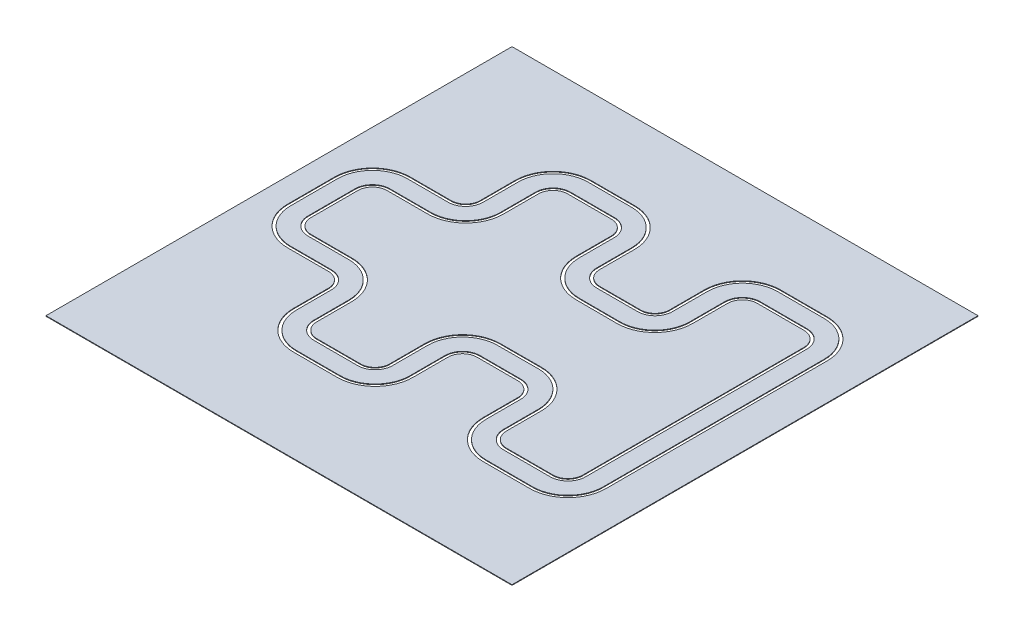
from build123d import *

# Parameters (mm, degrees)
BOSS_EXTRUDE1_DEPTH   = 10
BOSS_EXTRUDE1_2_DEPTH = 10
SKETCH1_W             = 8000
SKETCH1_H             = 8000
BOSS_EXTRUDE1_3_DEPTH = 10


with BuildPart() as part:
    # Sketch1 → Boss-Extrude1 (new body)
    with BuildSketch(Plane(origin=(0, 0, 0), x_dir=(1, 0, 0), z_dir=(0, 1, 0))):
        with BuildLine():
            Line((-1771.800598165, -1038.917055483), (-1771.800598165, -1638.917055483))
            ThreePointArc((-1771.800598165, -1638.917055483), (-1698.577293461, -1815.69375078), (-1521.800598165, -1888.917055483))
            Line((-1521.800598165, -1888.917055483), (-770.59837107, -1888.917055483))
            ThreePointArc((-770.59837107, -1888.917055483), (-593.821675773, -1815.69375078), (-520.59837107, -1638.917055483))
            Line((-520.59837107, -1638.917055483), (-520.59837107, -1037.241131973))
            ThreePointArc((-520.59837107, -1037.241131973), (-330.810688722, -578.215399925), (127.723544874, -387.243298104))
            Line((127.723544874, -387.243298104), (827.921145778, -385.435614494))
            ThreePointArc((827.921145778, -385.435614494), (1288.624961882, -575.221130711), (1479.599229835, -1035.433448363))
            Line((1479.599229835, -1035.433448363), (1479.599229835, -1633.753192334))
            ThreePointArc((1479.599229835, -1633.753192334), (1554.343425249, -1814.201642611), (1734.791875526, -1888.945838025))
            Line((1734.791875526, -1888.945838025), (2534.791875526, -1888.945838025))
            ThreePointArc((2534.791875526, -1888.945838025), (2715.240325804, -1814.201642611), (2789.984521218, -1633.753192334))
            Line((2789.984521218, -1633.753192334), (2789.984521218, -1035.433448363))
            Line((2789.984521218, -1035.433448363), (2789.984521218, 1563.280738064))
            Line((2789.984521218, 1563.280738064), (2789.984521218, 2161.600482035))
            ThreePointArc((2789.984521218, 2161.600482035), (2715.240326037, 2342.04893175), (2534.791876322, 2416.793126931))
            Line((2534.791876322, 2416.793126931), (1734.791876322, 2416.793126931))
            ThreePointArc((1734.791876322, 2416.793126931), (1554.343425811, 2342.04893208), (1479.599229835, 2161.600482035))
            Line((1479.599229835, 2161.600482035), (1479.599229835, 1563.280738064))
            ThreePointArc((1479.599229835, 1563.280738064), (1288.624961882, 1103.068420413), (827.921145778, 913.282904196))
            Line((827.921145778, 913.282904196), (127.723544874, 915.090587806))
            ThreePointArc((127.723544874, 915.090587806), (-330.810688722, 1106.062689627), (-520.59837107, 1565.088421674))
            Line((-520.59837107, 1565.088421674), (-520.59837107, 2166.764345185))
            ThreePointArc((-520.59837107, 2166.764345185), (-593.821675773, 2343.541040481), (-770.59837107, 2416.764345185))
            Line((-770.59837107, 2416.764345185), (-1521.800598165, 2416.764345185))
            ThreePointArc((-1521.800598165, 2416.764345185), (-1698.577293461, 2343.541040481), (-1771.800598165, 2166.764345185))
            Line((-1771.800598165, 2166.764345185), (-1771.800598165, 1566.764345185))
            ThreePointArc((-1771.800598165, 1566.764345185), (-1962.181190393, 1107.144937413), (-2421.800598165, 916.764345185))
            Line((-2421.800598165, 916.764345185), (-3121.800598165, 916.764345185))
            ThreePointArc((-3121.800598165, 916.764345185), (-3298.577293461, 843.541040481), (-3371.800598165, 666.764345185))
            Line((-3371.800598165, 666.764345185), (-3371.800598165, -138.917055483))
            ThreePointArc((-3371.800598165, -138.917055483), (-3298.577293461, -315.69375078), (-3121.800598165, -388.917055483))
            Line((-3121.800598165, -388.917055483), (-2421.800598165, -388.917055483))
            ThreePointArc((-2421.800598165, -388.917055483), (-1962.181190393, -579.297647712), (-1771.800598165, -1038.917055483))
        make_face()
    extrude(amount=BOSS_EXTRUDE1_DEPTH)


with BuildPart() as body_2:
    # Sketch1 → Boss-Extrude1 2 (new body)
    with BuildSketch(Plane(origin=(0, 0, 0), x_dir=(1, 0, 0), z_dir=(0, 1, 0))):
        with BuildLine():
            Line((-2121.800598165, -1638.917055483), (-2121.800598165, -1038.917055483))
            ThreePointArc((-2121.800598165, -1038.917055483), (-2209.668563809, -826.785021127), (-2421.800598165, -738.917055483))
            Line((-2421.800598165, -738.917055483), (-3121.800598165, -738.917055483))
            ThreePointArc((-3121.800598165, -738.917055483), (-3546.064666876, -563.181124195), (-3721.800598165, -138.917055483))
            Line((-3721.800598165, -138.917055483), (-3721.800598165, 666.764345185))
            ThreePointArc((-3721.800598165, 666.764345185), (-3546.064666876, 1091.028413897), (-3121.800598165, 1266.764345185))
            Line((-3121.800598165, 1266.764345185), (-2421.800598165, 1266.764345185))
            ThreePointArc((-2421.800598165, 1266.764345185), (-2209.668563809, 1354.632310829), (-2121.800598165, 1566.764345185))
            Line((-2121.800598165, 1566.764345185), (-2121.800598165, 2166.764345185))
            ThreePointArc((-2121.800598165, 2166.764345185), (-1946.064666876, 2591.028413897), (-1521.800598165, 2766.764345185))
            Line((-1521.800598165, 2766.764345185), (-770.59837107, 2766.764345185))
            ThreePointArc((-770.59837107, 2766.764345185), (-346.334302358, 2591.028413897), (-170.59837107, 2166.764345185))
            Line((-170.59837107, 2166.764345185), (-170.59837107, 1566.764201952))
            ThreePointArc((-170.59837107, 1566.764201952), (-82.730456066, 1354.632218237), (129.401485698, 1266.764201952))
            Line((129.401485698, 1266.764201952), (829.757148713, 1266.763867573))
            ThreePointArc((829.757148713, 1266.763867573), (1041.88927538, 1354.631782296), (1129.757291945, 1566.763866778))
            Line((1129.757291945, 1566.763866778), (1129.757291945, 2166.763723545))
            ThreePointArc((1129.757291945, 2166.763723545), (1308.781633859, 2591.261720351), (1734.791876322, 2766.657095451))
            Line((1734.791876322, 2766.657095451), (2534.791876322, 2766.657095451))
            ThreePointArc((2534.791876322, 2766.657095451), (2960.802117709, 2591.261720304), (3139.826459107, 2166.763724341))
            Line((3139.826459107, 2166.763724341), (3139.826459107, 1566.763867573))
            Line((3139.826459107, 1566.763867573), (3139.826459107, -1038.916577872))
            Line((3139.826459107, -1038.916577872), (3139.826459107, -1638.916434639))
            ThreePointArc((3139.826459107, -1638.916434639), (2960.802117476, -2063.414431165), (2534.791875526, -2238.809806545))
            Line((2534.791875526, -2238.809806545), (1734.791875526, -2238.809806545))
            ThreePointArc((1734.791875526, -2238.809806545), (1308.781633576, -2063.414431165), (1129.757291945, -1638.916434639))
            Line((1129.757291945, -1638.916434639), (1129.757291945, -1038.916577872))
            ThreePointArc((1129.757291945, -1038.916577872), (1041.889275661, -826.784492876), (829.757148713, -738.916577872))
            Line((829.757148713, -738.916577872), (129.401485698, -738.916912251))
            ThreePointArc((129.401485698, -738.916912251), (-82.730456066, -826.784928535), (-170.59837107, -1038.916912251))
            Line((-170.59837107, -1038.916912251), (-170.59837107, -1638.917055483))
            ThreePointArc((-170.59837107, -1638.917055483), (-346.334302358, -2063.181124195), (-770.59837107, -2238.917055483))
            Line((-770.59837107, -2238.917055483), (-1521.800598165, -2238.917055483))
            ThreePointArc((-1521.800598165, -2238.917055483), (-1946.064666876, -2063.181124195), (-2121.800598165, -1638.917055483))
        make_face()
        with BuildLine():
            Line((-1821.800598165, -1638.917055483), (-1821.800598165, -1038.917055483))
            ThreePointArc((-1821.800598165, -1038.917055483), (-1997.536529453, -614.652986771), (-2421.800598165, -438.917055483))
            Line((-2421.800598165, -438.917055483), (-3121.800598165, -438.917055483))
            ThreePointArc((-3121.800598165, -438.917055483), (-3333.932632521, -351.049089839), (-3421.800598165, -138.917055483))
            Line((-3421.800598165, -138.917055483), (-3421.800598165, 666.764345185))
            ThreePointArc((-3421.800598165, 666.764345185), (-3333.932632521, 878.896379541), (-3121.800598165, 966.764345185))
            Line((-3121.800598165, 966.764345185), (-2421.800598165, 966.764345185))
            ThreePointArc((-2421.800598165, 966.764345185), (-1997.536529453, 1142.500276473), (-1821.800598165, 1566.764345185))
            Line((-1821.800598165, 1566.764345185), (-1821.800598165, 2166.764345185))
            ThreePointArc((-1821.800598165, 2166.764345185), (-1733.932632521, 2378.896379541), (-1521.800598165, 2466.764345185))
            Line((-1521.800598165, 2466.764345185), (-770.59837107, 2466.764345185))
            ThreePointArc((-770.59837107, 2466.764345185), (-558.466336714, 2378.896379541), (-470.59837107, 2166.764345185))
            Line((-470.59837107, 2166.764345185), (-470.59837107, 1565.13607002))
            ThreePointArc((-470.59837107, 1565.13607002), (-295.438512025, 1141.448856815), (127.771144374, 965.138285424))
            Line((127.771144374, 965.138285424), (828.007668046, 963.235403668))
            ThreePointArc((828.007668046, 963.235403668), (1253.325364496, 1138.393047592), (1429.638151012, 1563.233187468))
            Line((1429.638151012, 1563.233187468), (1429.638151012, 2161.60048124))
            ThreePointArc((1429.638151012, 2161.60048124), (1519.023398428, 2377.384539677), (1734.813910867, 2466.754204959))
            Line((1734.813910867, 2466.754204959), (2534.791876322, 2466.754204959))
            ThreePointArc((2534.791876322, 2466.754204959), (2750.568143105, 2377.376748819), (2839.945599245, 2161.600482035))
            Line((2839.945599245, 2161.600482035), (2839.945599245, 1563.233188264))
            Line((2839.945599245, 1563.233188264), (2839.945599245, -1035.385898562))
            Line((2839.945599245, -1035.385898562), (2839.945599245, -1633.753192334))
            ThreePointArc((2839.945599245, -1633.753192334), (2750.560352343, -1849.537249927), (2534.769840981, -1938.906915257))
            Line((2534.769840981, -1938.906915257), (1734.791875526, -1938.906915257))
            ThreePointArc((1734.791875526, -1938.906915257), (1519.015608743, -1849.529459117), (1429.638152603, -1633.753192334))
            Line((1429.638152603, -1633.753192334), (1429.638152603, -1035.385898562))
            ThreePointArc((1429.638152603, -1035.385898562), (1253.325365807, -610.545757607), (828.007668046, -435.388113966))
            Line((828.007668046, -435.388113966), (127.771144374, -437.290995722))
            ThreePointArc((127.771144374, -437.290995722), (-295.438512025, -613.601567114), (-470.59837107, -1037.288780318))
            Line((-470.59837107, -1037.288780318), (-470.59837107, -1638.917055483))
            ThreePointArc((-470.59837107, -1638.917055483), (-558.466336714, -1851.049089839), (-770.59837107, -1938.917055483))
            Line((-770.59837107, -1938.917055483), (-1521.800598165, -1938.917055483))
            ThreePointArc((-1521.800598165, -1938.917055483), (-1733.932632521, -1851.049089839), (-1821.800598165, -1638.917055483))
        make_face(mode=Mode.SUBTRACT)
    extrude(amount=BOSS_EXTRUDE1_2_DEPTH)


with BuildPart() as body_3:
    # Sketch1 → Boss-Extrude1 3 (new body)
    with BuildSketch(Plane(origin=(0, 0, 0), x_dir=(1, 0, 0), z_dir=(0, 1, 0))):
        with Locations((-187.767761811, 128.325242378)):
            Rectangle(SKETCH1_W, SKETCH1_H)
        with BuildLine():
            Line((-2171.800598165, -1038.917055483), (-2171.800598165, -1638.917055483))
            ThreePointArc((-2171.800598165, -1638.917055483), (-1981.420005936, -2098.536463254), (-1521.800598165, -2288.917055483))
            Line((-1521.800598165, -2288.917055483), (-770.59837107, -2288.917055483))
            ThreePointArc((-770.59837107, -2288.917055483), (-310.978963298, -2098.536463254), (-120.59837107, -1638.917055483))
            Line((-120.59837107, -1638.917055483), (-120.59837107, -1038.925592351))
            ThreePointArc((-120.59837107, -1038.925592351), (-47.372048154, -862.145878893), (129.410165652, -788.925592497))
            Line((129.410165652, -788.925592497), (829.771954216, -788.949507672))
            ThreePointArc((829.771954216, -788.949507672), (1006.543130952, -862.175830443), (1079.763417494, -1038.949507526))
            Line((1079.763417494, -1038.949507526), (1079.763417494, -1638.958044103))
            ThreePointArc((1079.763417494, -1638.958044103), (1273.446052062, -2098.779430825), (1734.791875526, -2288.802328898))
            Line((1734.791875526, -2288.802328898), (2534.791875526, -2288.802328898))
            ThreePointArc((2534.791875526, -2288.802328898), (2996.137698991, -2098.779430825), (3189.820333559, -1638.958044103))
            Line((3189.820333559, -1638.958044103), (3189.820333559, -1038.949507526))
            Line((3189.820333559, -1038.949507526), (3189.820333559, 1566.796797228))
            Line((3189.820333559, 1566.796797228), (3189.820333559, 2166.805333804))
            ThreePointArc((3189.820333559, 2166.805333804), (2996.137699224, 2626.626719965), (2534.791876322, 2816.649617805))
            Line((2534.791876322, 2816.649617805), (1734.791876322, 2816.649617805))
            ThreePointArc((1734.791876322, 2816.649617805), (1273.446052344, 2626.626720012), (1079.763417494, 2166.805333009))
            Line((1079.763417494, 2166.805333009), (1079.763417494, 1566.796796433))
            ThreePointArc((1079.763417494, 1566.796796433), (1006.543130671, 1390.023119863), (829.771954216, 1316.796797374))
            Line((829.771954216, 1316.796797374), (129.410165652, 1316.772882198))
            ThreePointArc((129.410165652, 1316.772882198), (-47.372048154, 1389.993168595), (-120.59837107, 1566.772882052))
            Line((-120.59837107, 1566.772882052), (-120.59837107, 2166.764345185))
            ThreePointArc((-120.59837107, 2166.764345185), (-310.978963298, 2626.383752956), (-770.59837107, 2816.764345185))
            Line((-770.59837107, 2816.764345185), (-1521.800598165, 2816.764345185))
            ThreePointArc((-1521.800598165, 2816.764345185), (-1981.420005936, 2626.383752956), (-2171.800598165, 2166.764345185))
            Line((-2171.800598165, 2166.764345185), (-2171.800598165, 1566.764345185))
            ThreePointArc((-2171.800598165, 1566.764345185), (-2245.023902868, 1389.987649888), (-2421.800598165, 1316.764345185))
            Line((-2421.800598165, 1316.764345185), (-3121.800598165, 1316.764345185))
            ThreePointArc((-3121.800598165, 1316.764345185), (-3581.420005936, 1126.383752956), (-3771.800598165, 666.764345185))
            Line((-3771.800598165, 666.764345185), (-3771.800598165, -138.917055483))
            ThreePointArc((-3771.800598165, -138.917055483), (-3581.420005936, -598.536463254), (-3121.800598165, -788.917055483))
            Line((-3121.800598165, -788.917055483), (-2421.800598165, -788.917055483))
            ThreePointArc((-2421.800598165, -788.917055483), (-2245.023902868, -862.140360186), (-2171.800598165, -1038.917055483))
        make_face(mode=Mode.SUBTRACT)
    extrude(amount=BOSS_EXTRUDE1_3_DEPTH)


solid = Compound([part.part, body_2.part, body_3.part])
